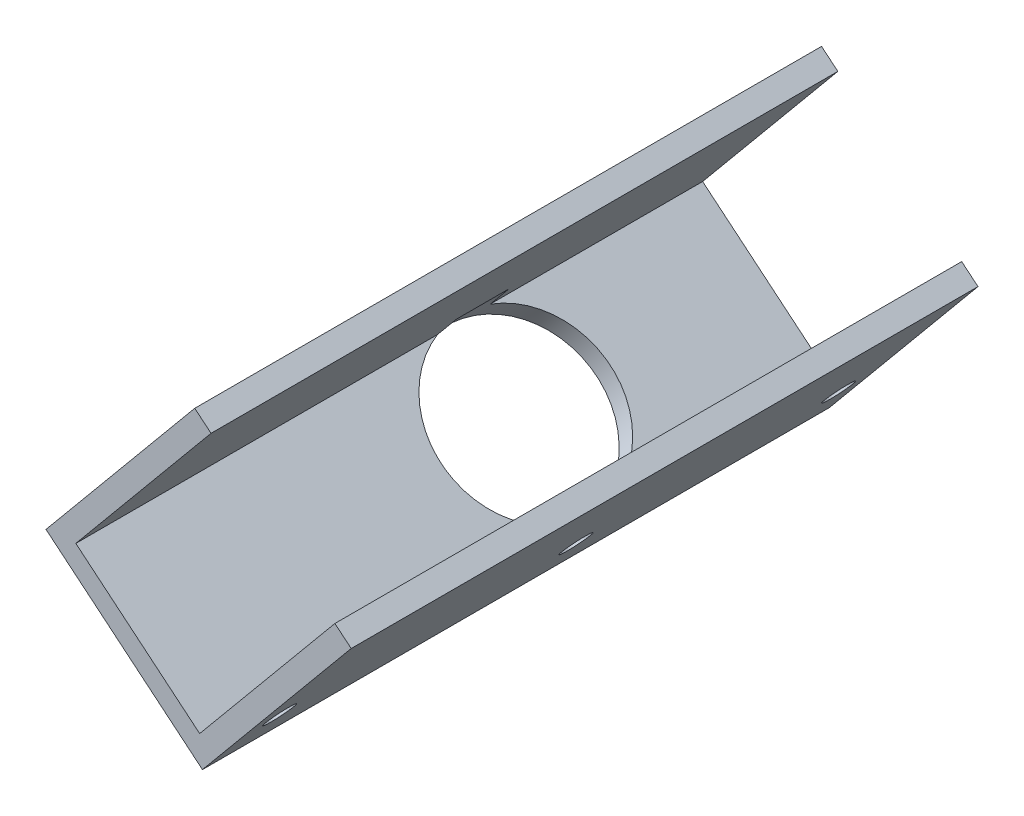
from build123d import *

# Parameters (mm, degrees)
ESTRUSIONE_SOTTILE1_DEPTH      = 37
ESTRUSIONE_SOTTILE1_DEPTH_BACK = 37
SCHIZZO2_R                     = 1.7
TAGLIO_ESTRUSIONE2_DEPTH       = 23
SCHIZZO3_R                     = 10
TAGLIO_ESTRUSIONE3_DEPTH       = 6
SCHIZZO4_W                     = 19
SCHIZZO4_H                     = 35
TAGLIO_ESTRUSIONE4_DEPTH       = 9
SCHIZZO5_R                     = 1.7
TAGLIO_ESTRUSIONE5_DEPTH       = 9
TAGLIO_ESTRUSIONE6_DEPTH       = 38
TAGLIO_ESTRUSIONE6_DEPTH_BACK  = 38


with BuildPart() as part:
    # Schizzo1 → Estrusione-Sottile1 (new body, two sides)
    with BuildSketch(Plane.XY) as estrusione_sottile1_sk:
        with BuildLine():
            Line((1.3418419, 31.371953403), (-14.62198067, 12.132505153))
            Line((-14.62198067, 12.132505153), (0, 0))
            Line((0, 0), (76.626348337, 92.349351598))
            ThreePointArc((76.626348337, 92.349351598), (100.821605793, 105.569380982), (125.016863249, 92.349351598))
            Line((125.016863249, 92.349351598), (132.637123428, 81.561358928))
            Line((132.637123428, 81.561358928), (153.805626203, 63.996914357))
            Line((153.805626203, 63.996914357), (152.209243946, 62.072969532))
            Line((152.209243946, 62.072969532), (130.786083182, 79.848715119))
            Line((130.786083182, 79.848715119), (122.942210931, 90.953275114))
            ThreePointArc((122.942210931, 90.953275114), (100.774095149, 103.069337988), (78.649981188, 90.873112409))
            Line((78.649981188, 90.873112409), (0.327562568, -3.520327082))
            Line((0.327562568, -3.520327082), (-18.142307752, 11.804942585))
            Line((-18.142307752, 11.804942585), (-0.582102925, 32.96833566))
            Line((-0.582102925, 32.96833566), (1.3418419, 31.371953403))
        make_face()
    extrude(amount=ESTRUSIONE_SOTTILE1_DEPTH)
    extrude(estrusione_sottile1_sk.sketch, amount=-ESTRUSIONE_SOTTILE1_DEPTH_BACK)

    # Schizzo2 → Taglio-Estrusione2 (cut)
    with BuildSketch(Plane(origin=(1.923944825, -1.596382257, 0), x_dir=(0, 0, -1), z_dir=(0.76957793, -0.638552903, 0))):
        with Locations((-6.552412565, 114.869422042)):
            Circle(SCHIZZO2_R)
        with Locations((-6.552412565, 104.052556993)):
            Circle(SCHIZZO2_R)
        with Locations((1.452296176, 109.710473024)):
            Circle(SCHIZZO2_R)
        with Locations((9.457004918, 104.551524007)):
            Circle(SCHIZZO2_R)
        with Locations((1.553386665, 98.82845624)):
            Circle(SCHIZZO2_R)
        with Locations((9.659185895, 93.604355486)):
            Circle(SCHIZZO2_R)
    extrude(amount=-TAGLIO_ESTRUSIONE2_DEPTH, mode=Mode.SUBTRACT)

    # Schizzo3 → Taglio-Estrusione3 (cut)
    with BuildSketch(Plane(origin=(-1.596382257, -1.923944825, 0), x_dir=(0.76957793, -0.638552903, 0), z_dir=(-0.638552903, -0.76957793, 0))):
        with Locations((-9.5, -8.811563563)):
            Circle(SCHIZZO3_R)
    extrude(amount=-TAGLIO_ESTRUSIONE3_DEPTH, mode=Mode.SUBTRACT)

    # Schizzo4 → Taglio-Estrusione4 (cut)
    with BuildSketch(Plane(origin=(0, 0, 0), x_dir=(0, 0, 1), z_dir=(-0.76957793, 0.638552903, 0))):
        with Locations((-7.5, 57.5)):
            Rectangle(SCHIZZO4_W, SCHIZZO4_H)
    extrude(amount=-TAGLIO_ESTRUSIONE4_DEPTH, mode=Mode.SUBTRACT)

    # Schizzo5 → Taglio-Estrusione5 (cut)
    with BuildSketch(Plane(origin=(0, 0, 0), x_dir=(0, 0, 1), z_dir=(-0.76957793, 0.638552903, 0))):
        with Locations((33, 5.5)):
            Circle(SCHIZZO5_R)
        with Locations((-33, 5.5)):
            Circle(SCHIZZO5_R)
        with Locations((-2, 5.5)):
            Circle(SCHIZZO5_R)
    extrude(amount=-TAGLIO_ESTRUSIONE5_DEPTH, mode=Mode.SUBTRACT)

    # Schizzo6 → Taglio-Estrusione6 (cut, two sides)
    with BuildSketch(Plane.XY) as taglio_estrusione6_sk:
        Polygon((1.3418419, 31.371953403), (32.99116726, 5.111106005), (167.345945228, 57.415127601), (141.955436185, 113.188092886), (32.984624639, 110.825582067), align=None)
    extrude(amount=TAGLIO_ESTRUSIONE6_DEPTH, mode=Mode.SUBTRACT)
    extrude(taglio_estrusione6_sk.sketch, amount=-TAGLIO_ESTRUSIONE6_DEPTH_BACK, mode=Mode.SUBTRACT)


solid = part.part
